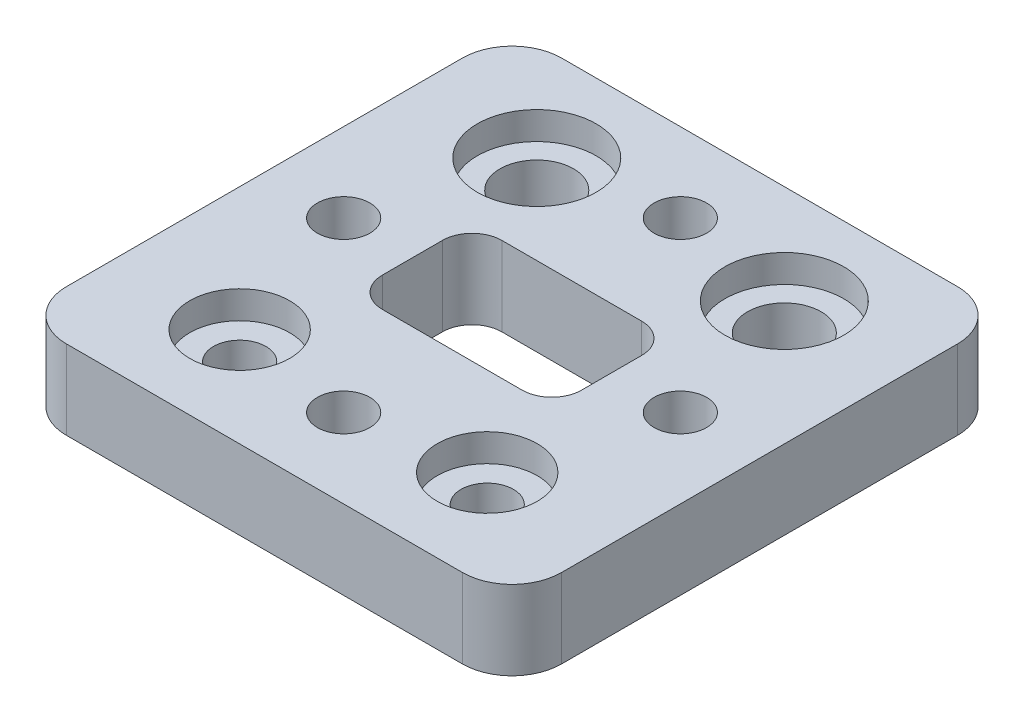
from build123d import *

# Parameters (mm, degrees)
CROQUIS1_R              = 2.65
CROQUIS1_R_2            = 3.72
SALIENTE_EXTRUIR2_DEPTH = 8
CORTAR_EXTRUIR1_START   = 8
CROQUIS1_4_R            = 5.05
CROQUIS1_4_R_2          = 6
CORTAR_EXTRUIR1_DEPTH   = 2.8


with BuildPart() as part:
    # Croquis1 → Saliente-Extruir2 (new body)
    with BuildSketch(Plane(origin=(0, 0, 0), x_dir=(1, 0, 0), z_dir=(0, 1, 0))):
        with BuildLine():
            Line((-20, -25), (20, -25))
            ThreePointArc((20, -25), (23.535533906, -23.535533906), (25, -20))
            Line((25, -20), (25, 20))
            ThreePointArc((25, 20), (23.535533906, 23.535533906), (20, 25))
            Line((20, 25), (-20, 25))
            ThreePointArc((-20, 25), (-23.535533906, 23.535533906), (-25, 20))
            Line((-25, 20), (-25, -20))
            ThreePointArc((-25, -20), (-23.535533906, -23.535533906), (-20, -25))
        make_face()
        with Locations((-12.5, -15)):
            Circle(CROQUIS1_R, mode=Mode.SUBTRACT)
        with Locations((-12.5, 15)):
            Circle(CROQUIS1_R_2, mode=Mode.SUBTRACT)
        with Locations((0, -17)):
            Circle(CROQUIS1_R, mode=Mode.SUBTRACT)
        with Locations((-17, 0)):
            Circle(CROQUIS1_R, mode=Mode.SUBTRACT)
        with Locations((0, 17)):
            Circle(CROQUIS1_R, mode=Mode.SUBTRACT)
        with Locations((17, 0)):
            Circle(CROQUIS1_R, mode=Mode.SUBTRACT)
        with Locations((12.5, -15)):
            Circle(CROQUIS1_R, mode=Mode.SUBTRACT)
        with Locations((12.5, 15)):
            Circle(CROQUIS1_R_2, mode=Mode.SUBTRACT)
        with BuildLine():
            Line((-7.060224725, -6.03567091), (7.060224725, -6.03567091))
            ThreePointArc((7.060224725, -6.03567091), (9.181545068, -5.156991253), (10.060224725, -3.03567091))
            Line((10.060224725, -3.03567091), (10.060224725, 3.03567091))
            ThreePointArc((10.060224725, 3.03567091), (9.181545068, 5.156991253), (7.060224725, 6.03567091))
            Line((7.060224725, 6.03567091), (-7.060224725, 6.03567091))
            ThreePointArc((-7.060224725, 6.03567091), (-9.181545068, 5.156991253), (-10.060224725, 3.03567091))
            Line((-10.060224725, 3.03567091), (-10.060224725, -3.03567091))
            ThreePointArc((-10.060224725, -3.03567091), (-9.181545068, -5.156991253), (-7.060224725, -6.03567091))
        make_face(mode=Mode.SUBTRACT)
    extrude(amount=SALIENTE_EXTRUIR2_DEPTH)

    # Croquis1_4 → Cortar-Extruir1 (cut)
    with BuildSketch(Plane(origin=(0, 0, 0), x_dir=(1, 0, 0), z_dir=(0, 1, 0)).offset(CORTAR_EXTRUIR1_START)):
        with Locations((-12.5, -15)):
            Circle(CROQUIS1_4_R)
        with Locations((-12.5, 15)):
            Circle(CROQUIS1_4_R_2)
        with Locations((12.5, -15)):
            Circle(CROQUIS1_4_R)
        with Locations((12.5, 15)):
            Circle(CROQUIS1_4_R_2)
    extrude(amount=-CORTAR_EXTRUIR1_DEPTH, mode=Mode.SUBTRACT)


solid = part.part
